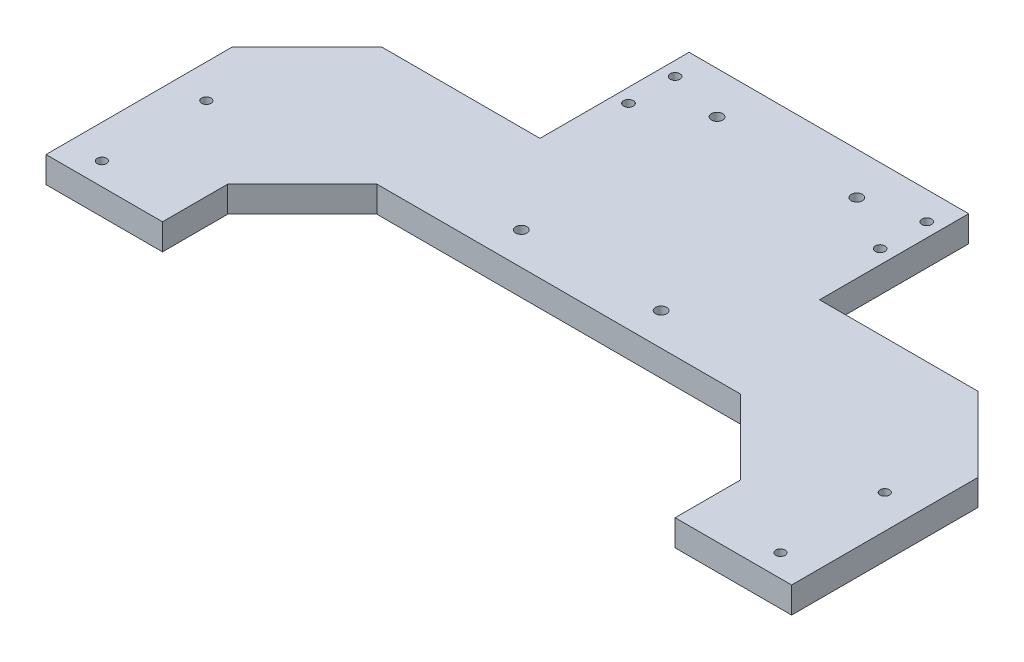
from build123d import *

# Parameters (mm, degrees)
BOSS_EXTRUDE1_DEPTH     = 14
SKETCH2_R               = 2.6
SKETCH2_R_2             = 2.5
SKETCH2_R_3             = 3
SKETCH2_W               = 275
SKETCH2_H               = 75
CUT_EXTRUDE1_DEPTH      = 1
CUT_EXTRUDE1_DEPTH_BACK = 15
CHAMFER1_SIZE           = 40


with BuildPart() as part:
    # Sketch1 → Boss-Extrude1 (new body)
    with BuildSketch(Plane(origin=(0, 0, 0), x_dir=(1, 0, 0), z_dir=(0, 1, 0))):
        Polygon((-75, -40), (-75, 40), (75, 40), (75, -40), (200, -40), (200, -180), (-200, -180), (-200, -40), align=None)
    extrude(amount=BOSS_EXTRUDE1_DEPTH)

    # Sketch2 → Cut-Extrude1 (cut, two sides)
    with BuildSketch(Plane(origin=(0, 14, 0), x_dir=(1, 0, 0), z_dir=(0, 1, 0))) as cut_extrude1_sk:
        with Locations((-67.5, 25)):
            Circle(SKETCH2_R)
        with Locations((-67.5, 0)):
            Circle(SKETCH2_R)
        with Locations((-182, -168)):
            Circle(SKETCH2_R_2)
        with Locations((-182, -112)):
            Circle(SKETCH2_R_2)
        with Locations((-37.5, 17.5)):
            Circle(SKETCH2_R_3)
        with Locations((-37.5, -87.5)):
            Circle(SKETCH2_R_3)
        with Locations((37.5, -87.5)):
            Circle(SKETCH2_R_3)
        with Locations((37.5, 17.5)):
            Circle(SKETCH2_R_3)
        with Locations((182, -112)):
            Circle(SKETCH2_R_2)
        with Locations((182, -168)):
            Circle(SKETCH2_R_2)
        with Locations((67.5, 0)):
            Circle(SKETCH2_R)
        with Locations((67.5, 25)):
            Circle(SKETCH2_R)
        with Locations((0, -142.5)):
            Rectangle(SKETCH2_W, SKETCH2_H)
    extrude(amount=CUT_EXTRUDE1_DEPTH, mode=Mode.SUBTRACT)
    extrude(cut_extrude1_sk.sketch, amount=-CUT_EXTRUDE1_DEPTH_BACK, mode=Mode.SUBTRACT)

    # Chamfer1
    chamfer1_edges = [part.edges().sort_by_distance(p)[0] for p in [
        (200, 7, 40),
        (-200, 7, 40),
        (-137.5, 7, 105),
        (137.5, 7, 105),
    ]]
    chamfer(chamfer1_edges, length=CHAMFER1_SIZE)


solid = part.part
